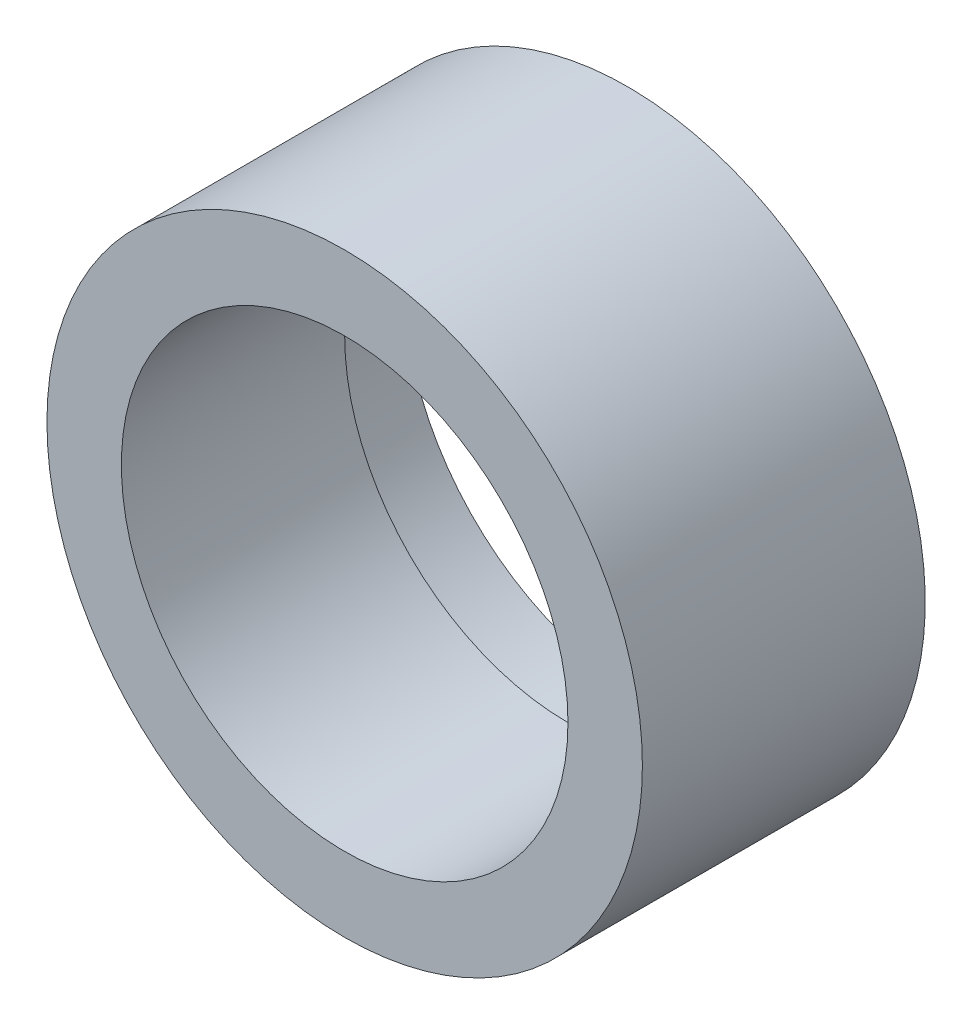
from build123d import *

# Parameters (mm, degrees)
SKETCH_1_R          = 20
EXTRUDE_1_DEPTH     = 20
SKETCH_4_R          = 20
SKETCH_4_R_2        = 18.5
CUT_EXTRUDE_3_DEPTH = 1
SKETCH_3_R          = 16
CUT_EXTRUDE_2_DEPTH = 5
SKETCH_6_R          = 15
CUT_EXTRUDE_4_DEPTH = 21


with BuildPart() as part:
    # ｽｹｯﾁ1 → ﾎﾞｽ - 押し出し1 (new body)
    with BuildSketch(Plane.XY):
        Circle(SKETCH_1_R)
    extrude(amount=EXTRUDE_1_DEPTH)

    # ｽｹｯﾁ4 → ｶｯﾄ - 押し出し3 (cut)
    with BuildSketch(Plane(origin=(0, 0, 0), x_dir=(-1, 0, 0), z_dir=(0, 0, -1))):
        Circle(SKETCH_4_R)
        Circle(SKETCH_4_R_2, mode=Mode.SUBTRACT)
    extrude(amount=-CUT_EXTRUDE_3_DEPTH, mode=Mode.SUBTRACT)

    # ｽｹｯﾁ3 → ｶｯﾄ - 押し出し2 (cut)
    with BuildSketch(Plane(origin=(0, 0, 0), x_dir=(-1, 0, 0), z_dir=(0, 0, -1))):
        Circle(SKETCH_3_R)
    extrude(amount=-CUT_EXTRUDE_2_DEPTH, mode=Mode.SUBTRACT)

    # ｽｹｯﾁ6 → ｶｯﾄ - 押し出し4 (cut, through all)
    with BuildSketch(Plane.XY.offset(20)):
        Circle(SKETCH_6_R)
    extrude(amount=-CUT_EXTRUDE_4_DEPTH, mode=Mode.SUBTRACT)


solid = part.part
